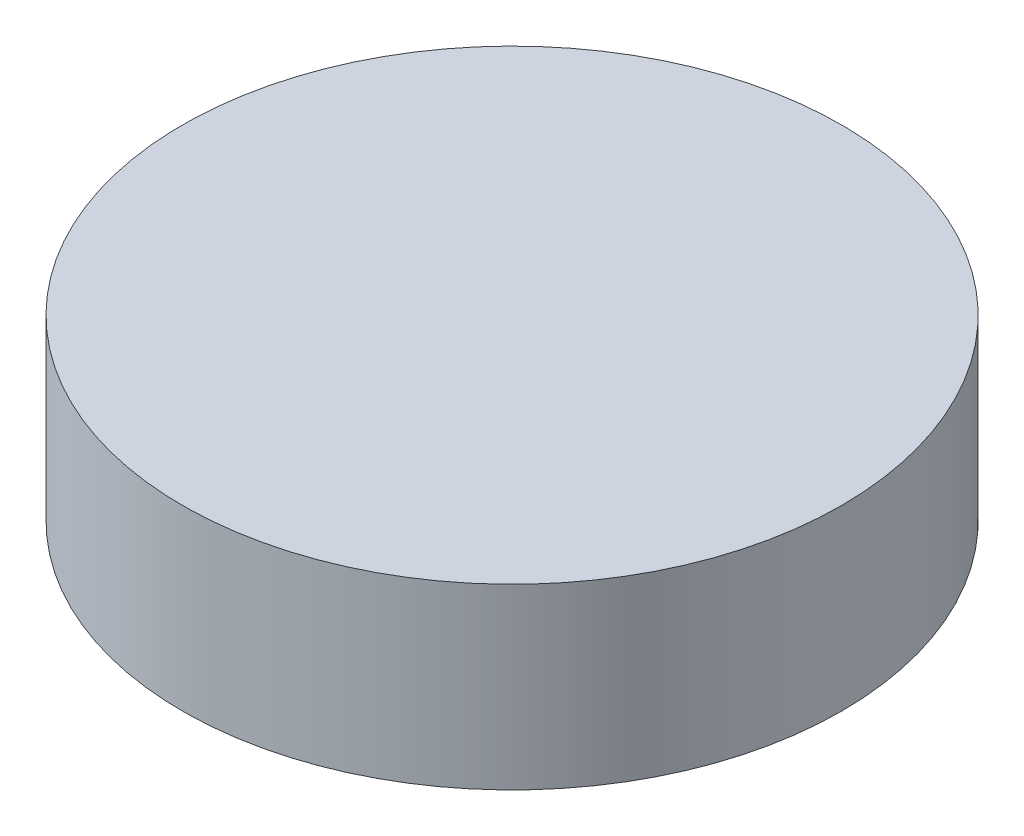
from build123d import *


with BuildPart() as part:
    # Esquisse1 → Révolution1 (revolve)
    with BuildSketch(Plane.XY):
        Polygon((0, 16), (22.5, 16), (22.5, 13), (37, 13), (37, 33), (0, 33), align=None)
    revolve(axis=Axis((0, 0, 0), (0, 1, 0)))


solid = part.part
